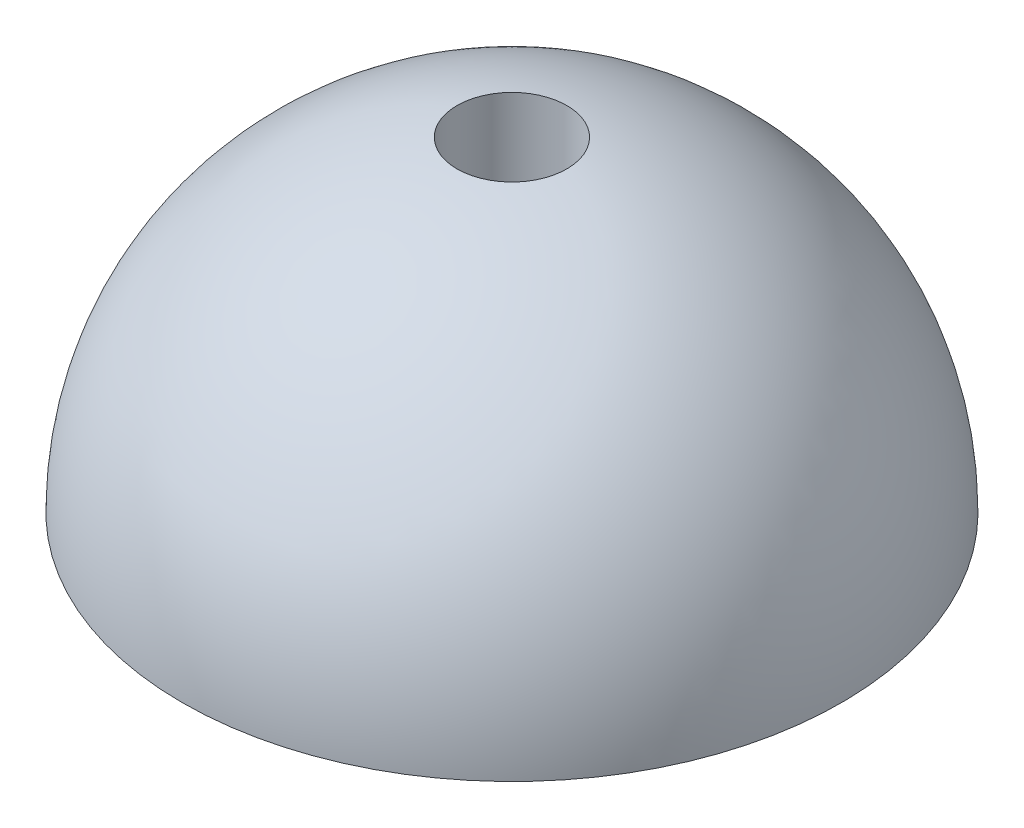
from build123d import *


with BuildPart() as part:
    # 草图2 → 旋转1 (revolve)
    with BuildSketch(Plane.XY):
        with BuildLine():
            Line((5, 0), (30, 0))
            ThreePointArc((30, 0), (22.912878475, 19.364916731), (5, 29.580398915))
            Line((5, 29.580398915), (5, 0))
        make_face()
    revolve(axis=Axis((0, 0, 0), (0, -1, 0)))


solid = part.part
